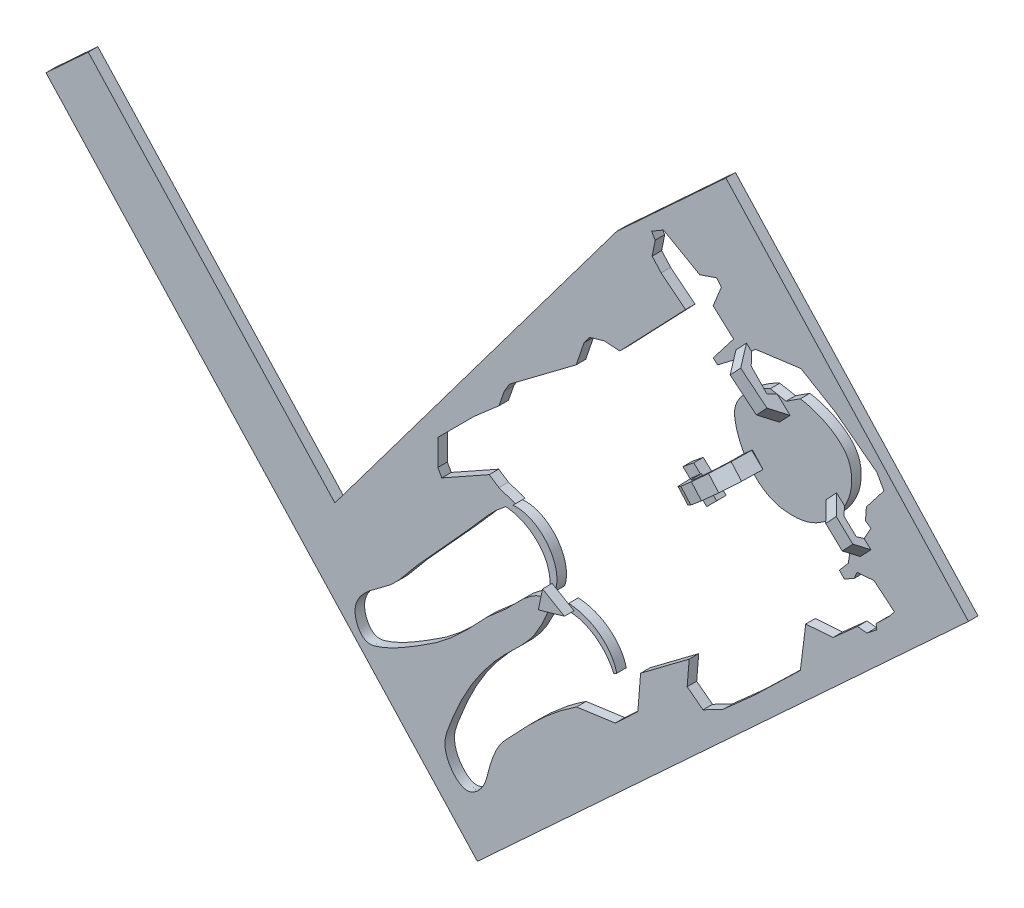
from build123d import *

# Parameters (mm, degrees)
BOSS_EXTRUDE1_DEPTH = 3
CUT_EXTRUDE2_DEPTH  = 4
BOSS_EXTRUDE2_DEPTH = 3
BOSS_EXTRUDE3_DEPTH = 10
CUT_EXTRUDE3_START  = -4.975278
CUT_EXTRUDE3_DEPTH  = 4.975278
CUT_EXTRUDE4_REACH  = 245.921
CUT_EXTRUDE5_REACH  = 5
BOSS_EXTRUDE4_DEPTH = 3


with BuildPart() as part:
    # Sketch2 → Boss-Extrude1 (new body)
    with BuildSketch(Plane.XY):
        Polygon((26.922556893, 113.42941639), (103.208588172, 30.795370629), (-51.225574888, -111.775034645), (-127.511606166, -29.140988884), align=None)
    extrude(amount=BOSS_EXTRUDE1_DEPTH)

    # Sketch1 → Cut-Extrude2 (cut, through all)
    with BuildSketch(Plane.XY):
        with BuildLine():
            Line((-28.489958544, -25.74262491), (-26.777947218, -26.002020566))
            add(Edge.make_bspline(
                [(-26.777947218, -26.002020566), (-24.018013375, -18.106298171), (-31.548102281, -8.361955091), (-40.007125648, -9.141302959)],
                knots=[0, 0, 0, 0, 1, 1, 1, 1], degree=3))
            Line((-40.007125648, -9.141302959), (-39.254993621, -8.389386271))
            Line((-39.254993621, -8.389386271), (-44.445814289, -6.578486289))
            Line((-44.445814289, -6.578486289), (-47.500022786, -4.575939423))
            Line((-47.500022786, -4.575939423), (-62.418910281, -12.928479529))
            Line((-62.418910281, -12.928479529), (-63.660041452, -10.711633388))
            Line((-63.660041452, -10.711633388), (-63.660041452, -2.500774179))
            Line((-63.660041452, -2.500774179), (-52.215861072, 8.940129688))
            Line((-52.215861072, 8.940129688), (-44.445814289, 15.695436772))
            Line((-44.445814289, 15.695436772), (-42.763063292, 20.518927158))
            Line((-42.763063292, 20.518927158), (-41.196901041, 23.195296585))
            Line((-41.196901041, 23.195296585), (-20.145077218, 38.999419398))
            Line((-20.145077218, 38.999419398), (-17.6967522, 46.243531572))
            Line((-17.6967522, 46.243531572), (-15.952319889, 48.586054961))
            Line((-15.952319889, 48.586054961), (-11.366954957, 49.931759887))
            Line((-11.366954957, 49.931759887), (-6.432703564, 49.632714348))
            Line((-6.432703564, 49.632714348), (14.241254679, 71.249155727))
            Line((14.241254679, 71.249155727), (6.559000162, 77.394959341))
            Line((6.559000162, 77.394959341), (3.729952218, 80.548180705))
            Line((3.729952218, 80.548180705), (4.678756683, 85.365187989))
            Line((4.678756683, 85.365187989), (3.583982301, 87.262796919))
            Line((3.583982301, 87.262796919), (7.306215202, 89.452345684))
            Line((7.306215202, 89.452345684), (18.691868782, 82.956684347))
            Line((18.691868782, 82.956684347), (24.019770778, 84.781308318))
            Line((24.019770778, 84.781308318), (25.479469955, 82.956684347))
            Line((25.479469955, 82.956684347), (22.924996395, 76.606992927))
            Line((22.924996395, 76.606992927), (29.347672773, 70.768196219))
            Line((29.347672773, 70.768196219), (22.924996395, 62.447910911))
            Line((22.924996395, 62.447910911), (24.311710613, 61.207166611))
            Line((24.311710613, 61.207166611), (29.274687815, 65.002384471))
            Line((29.274687815, 65.002384471), (36.208258905, 71.425060849))
            Line((36.208258905, 71.425060849), (50.513310839, 73.322669779))
            Line((50.513310839, 73.322669779), (61.409052821, 66.851112701))
            Line((61.409052821, 66.851112701), (74.409230739, 57.011199028))
            Line((74.409230739, 57.011199028), (76.635780549, 53.060868721))
            Line((76.635780549, 53.060868721), (71.105318119, 45.950274169))
            Line((71.105318119, 45.950274169), (70.81802137, 41.999943863))
            Line((70.81802137, 41.999943863), (72.541801867, 40.850756864))
            Line((72.541801867, 40.850756864), (68.735119935, 33.955634874))
            Line((68.735119935, 33.955634874), (67.011339438, 33.093744626))
            Line((67.011339438, 33.093744626), (65.143910565, 33.093744626))
            Line((65.143910565, 33.093744626), (64.641141254, 32.447326939))
            Line((64.641141254, 32.447326939), (65.862152439, 30.795370629))
            Line((65.862152439, 30.795370629), (65.425488605, 27.749926294))
            Line((65.425488605, 27.749926294), (62.609522619, 24.464632644))
            Line((62.609522619, 24.464632644), (64.180832267, 22.807847382))
            Line((64.180832267, 22.807847382), (67.318487341, 24.594567632))
            Line((67.318487341, 24.594567632), (68.146479652, 26.642759139))
            Line((68.146479652, 26.642759139), (73.506640403, 27.078544566))
            Line((73.506640403, 27.078544566), (79.912686178, 21.761962358))
            Line((79.912686178, 21.761962358), (78.300280099, 19.713770851))
            Line((78.300280099, 19.713770851), (74.160318543, 15.704544924))
            Line((74.160318543, 15.704544924), (74.378211256, 14.092138844))
            Line((74.378211256, 14.092138844), (71.327713268, 11.695318996))
            Line((71.327713268, 11.695318996), (68.27721528, 11.956790252))
            Line((68.27721528, 11.956790252), (60.607391766, 5.11495905))
            Line((60.607391766, 5.11495905), (52.022418856, 4.504859452))
            Line((52.022418856, 4.504859452), (50.345289639, -8.970089581))
            Line((50.345289639, -8.970089581), (35.925054251, -22.907863562))
            Line((35.925054251, -22.907863562), (25.978409584, -31.768961788))
            Line((25.978409584, -31.768961788), (19.727031388, -35.01334794))
            Line((19.727031388, -35.01334794), (14.741755105, -31.215042201))
            Line((14.741755105, -31.215042201), (15.374806061, -23.381036613))
            Line((15.374806061, -23.381036613), (0.102451734, -34.855085201))
            Line((0.102451734, -34.855085201), (-0.767993331, -45.775214202))
            Line((-0.767993331, -45.775214202), (-7.889816592, -52.422249245))
            Line((-7.889816592, -52.422249245), (-20.0495368, -54.114765272))
            add(Edge.make_bspline(
                [(-20.0495368, -54.114765272), (-26.638754805, -58.369140626), (-33.60084356, -64.753121816), (-40.776234735, -72.668213602), (-43.981367902, -75.838743159), (-46.08276872, -79.92643426), (-47.813940662, -85.193845066), (-48.789061689, -90.829908431), (-54.655476202, -95.651762177), (-60.505648294, -90.409296458), (-61.905644789, -84.91793666), (-60.513710963, -80.245245569), (-58.394501994, -74.983722847), (-53.542503488, -64.194627923), (-44.877269676, -52.627051728), (-32.709657691, -42.177711477), (-29.344355907, -33.601737985), (-27.428619767, -29.2414519)],
                knots=[0, 0, 0, 0, 0.177151493, 0.212774791, 0.242683049, 0.278781057, 0.31557073, 0.368257713, 0.408422005, 0.457109138, 0.51138757, 0.531457482, 0.566383124, 0.640421191, 0.799022749, 0.889920165, 1, 1, 1, 1], degree=3))
            add(Edge.make_bspline(
                [(-27.428619767, -29.2414519), (-29.766091897, -28.73813973), (-35.843115522, -31.124394132), (-40.975902307, -37.899299765), (-47.663504833, -42.891133427), (-54.132922978, -50.231431914), (-61.941283841, -57.578344671), (-72.498779433, -63.964977162), (-79.295517027, -68.035323705), (-87.345509671, -70.461319567), (-91.287617477, -62.239422997), (-86.028029249, -54.905466247), (-77.622767235, -50.31610948), (-71.087453798, -41.370933022), (-61.940687362, -31.538575642), (-52.391107819, -21.189116729), (-45.848198972, -13.293309029), (-42.35260779, -10.711633388)],
                knots=[0, 0, 0, 0, 0.046259443, 0.121305997, 0.166362934, 0.21146717, 0.315556578, 0.378654398, 0.454547961, 0.479099412, 0.531003329, 0.580271611, 0.646093429, 0.719896994, 0.79661339, 0.914198506, 1, 1, 1, 1], degree=3))
            add(Edge.make_bspline(
                [(-42.35260779, -10.711633388), (-34.872933131, -11.126916445), (-27.529906458, -17.641261098), (-28.489958544, -25.74262491)],
                knots=[0, 0, 0, 0, 1, 1, 1, 1], degree=3))
        make_face()
        with BuildLine():
            Line((-22.527334014, -27.155786851), (-23.40613173, -29.2414519))
            add(Edge.make_bspline(
                [(-23.40613173, -29.2414519), (-16.891458747, -28.84293542), (-10.866251435, -33.38666007), (-8.327813037, -39.135187285)],
                knots=[0, 0, 0, 0, 1, 1, 1, 1], degree=3))
            Line((-8.327813037, -39.135187285), (-7.40276281, -38.627830109))
            add(Edge.make_bspline(
                [(-22.527334014, -27.155786851), (-15.855913681, -27.334955864), (-8.990488923, -31.983561793), (-7.40276281, -38.627830109)],
                knots=[0, 0, 0, 0, 1, 1, 1, 1], degree=3))
        make_face(mode=Mode.SUBTRACT)
        Polygon((16.809751514, 30.795370629), (24.019770778, 24.040944484), (20.895698397, 20.902705889), (13.416342778, 28.063449625), align=None, mode=Mode.SUBTRACT)
        with BuildLine():
            Line((40.894149513, 63.040583617), (45.842126954, 62.093836467))
            Line((45.842126954, 62.093836467), (50.345289639, 65.002384471))
            add(Edge.make_bspline(
                [(50.345289639, 65.002384471), (55.706835159, 64.16039739), (65.013127395, 60.35694657), (66.744327078, 50.964887115), (65.964636666, 45.238483295), (61.595280962, 38.057424142), (54.971897133, 32.630188015), (47.360626471, 31.706721063), (40.286123989, 32.799293943), (33.367509941, 38.868912594), (30.18507545, 45.866540088), (28.873647274, 55.982923513), (36.646603813, 61.19198859), (40.894149513, 63.040583617)],
                knots=[0, 0, 0, 0, 0.19484687, 0.224840607, 0.288103897, 0.367003622, 0.479066444, 0.534321932, 0.598078789, 0.692932946, 0.801565557, 0.828048035, 1, 1, 1, 1], degree=3))
        make_face(mode=Mode.SUBTRACT)
    extrude(amount=CUT_EXTRUDE2_DEPTH, mode=Mode.SUBTRACT)

    # Sketch3 → Boss-Extrude2 (add)
    with BuildSketch(Plane.XY.offset(3)):
        Polygon((-27.738560258, -24.314057297), (-20.849085299, -28.328397037), (-29.040508282, -30.661053913), align=None)
    extrude(amount=BOSS_EXTRUDE2_DEPTH)

    # Sketch4 → Boss-Extrude3 (add)
    with BuildSketch(Plane.XY.offset(3)):
        Polygon((33.406037678, 71.721474536), (74.32768067, 33.314569381), (71.010532386, 29.780226864), (30.088889394, 68.187132019), align=None)
        Polygon((15.676606283, 25.899470727), (35.26372351, 43.564266503), (38.596092825, 39.86926152), (19.030247217, 22.68869101), align=None)
    extrude(amount=BOSS_EXTRUDE3_DEPTH)

    # Sketch5 → Cut-Extrude3 (cut)
    with BuildSketch(Plane(origin=(-2.964127381, 3.375653833, 0), x_dir=(0.751424923, 0.659818601, 0), z_dir=(0.659818601, -0.751424923, 0)).offset(CUT_EXTRUDE3_START)):
        Polygon((33.689245206, 3), (34.705591038, 7.118830306), (40.067374102, 10.358222346), (46.150516958, 10.358222346), (50.844515474, 7.475677964), (51.369452617, 3), align=None)
        Polygon((29.270222393, 3), (31.241978696, 8.574278918), (37.187098079, 12.087713), (42.862925495, 13), (48.894835931, 12.087713), (53.747885492, 8.574278918), (55.308546406, 3), (55.308546406, 13), (43.247517835, 14.516447601), (29.270222393, 13), (28.868745193, 13), (28.868745193, 3), align=None)
    extrude(amount=CUT_EXTRUDE3_DEPTH, mode=Mode.SUBTRACT)

    # Sketch7 → Cut-Extrude4 (cut, up to next)
    with BuildSketch(Plane(origin=(51.433837048, 54.801528759, 0), x_dir=(0.729155994, -0.684347526, 0), z_dir=(0.684347526, 0.729155994, 0)), mode=Mode.PRIVATE) as cut_extrude4_sk1:
        Polygon((-24.724201002, -3), (-20.54746791, -7.876151521), (-9.916863195, -7.364931386), (-5.952483934, -3), (14.168517243, -3), (18.691881781, -6.434488147), (25.849581596, -6.434488147), (28.939735893, -3), (31.397730796, -3), (31.397730796, -13), (-24.724201002, -13), align=None)
    cut_extrude4_tool1 = extrude(cut_extrude4_sk1.sketch, amount=-CUT_EXTRUDE4_REACH, mode=Mode.PRIVATE) & part.part
    add(cut_extrude4_tool1.solids().sort_by_distance((54.794438, 51.647446, 8.720228))[0], mode=Mode.SUBTRACT)
    # Sketch7 → Cut-Extrude4 (cut, up to next)
    with BuildSketch(Plane(origin=(51.433837048, 54.801528759, 0), x_dir=(0.729155994, -0.684347526, 0), z_dir=(0.684347526, 0.729155994, 0)), mode=Mode.PRIVATE) as cut_extrude4_sk2:
        Polygon((17.628527, -3), (19.387018884, -4.582189549), (24.835284443, -4.582189549), (26.025889681, -3), align=None)
    cut_extrude4_tool2 = extrude(cut_extrude4_sk2.sketch, amount=-CUT_EXTRUDE4_REACH, mode=Mode.PRIVATE) & part.part
    add(cut_extrude4_tool2.solids().sort_by_distance((67.445447, 39.773873, 3.734927))[0], mode=Mode.SUBTRACT)
    # Sketch7 → Cut-Extrude4 (cut, up to next)
    with BuildSketch(Plane(origin=(51.433837048, 54.801528759, 0), x_dir=(0.729155994, -0.684347526, 0), z_dir=(0.684347526, 0.729155994, 0)), mode=Mode.PRIVATE) as cut_extrude4_sk3:
        Polygon((-22.59726616, -3), (-19.735892804, -5.153197199), (-12.697316906, -5.395272628), (-11.420775647, -3), align=None)
    cut_extrude4_tool3 = extrude(cut_extrude4_sk3.sketch, amount=-CUT_EXTRUDE4_REACH, mode=Mode.PRIVATE) & part.part
    add(cut_extrude4_tool3.solids().sort_by_distance((39.370702, 66.123354, 4.050171))[0], mode=Mode.SUBTRACT)

    # Sketch8 → Cut-Extrude5 (cut, up to next)
    with BuildSketch(Plane.XY.offset(3), mode=Mode.PRIVATE) as cut_extrude5_sk1:
        Polygon((-7.413973567, 81.730646077), (-107.074473146, -51.278763742), (-127.511606166, -29.140988884), align=None)
    cut_extrude5_tool1 = extrude(cut_extrude5_sk1.sketch, amount=-CUT_EXTRUDE5_REACH, mode=Mode.PRIVATE) & part.part
    add(cut_extrude5_tool1.solids().sort_by_distance((-80.666684, 0.436964, 3))[0], mode=Mode.SUBTRACT)

    # Sketch9 → Boss-Extrude4 (add)
    with BuildSketch(Plane.XY):
        Polygon((-107.074473146, -51.278763742), (-186.889709483, 35.178163974), (-173.587669519, 47.458330429), (-96.036054489, -36.546612518), align=None)
    extrude(amount=BOSS_EXTRUDE4_DEPTH)


solid = part.part
